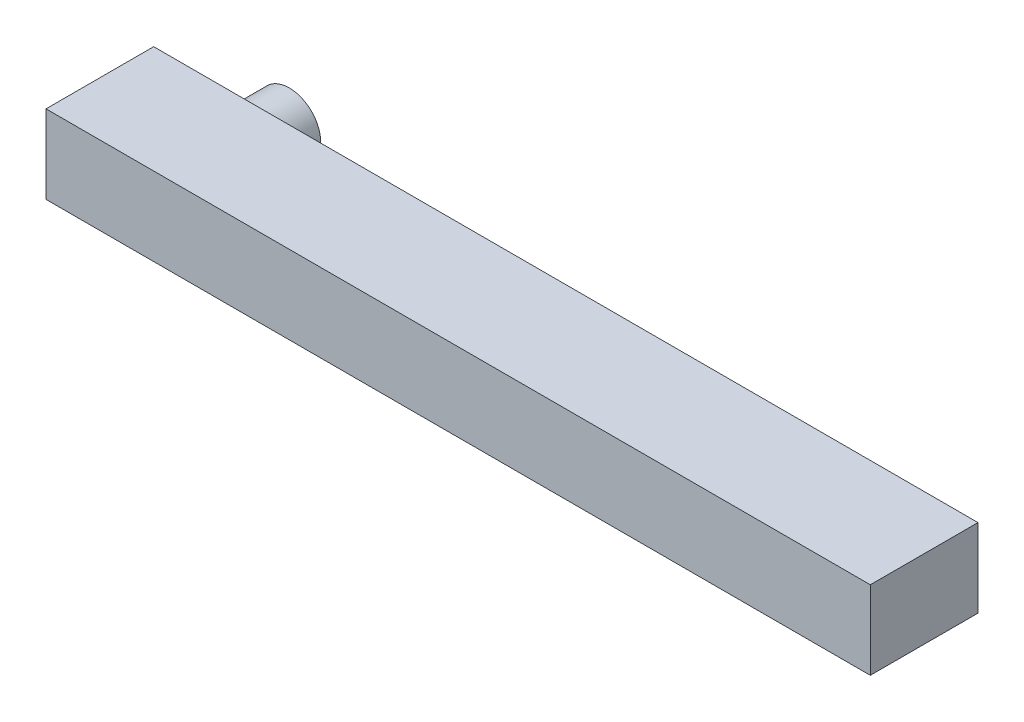
from build123d import *

# Parameters (mm, degrees)
SKETCH1_W           = 62
SKETCH1_H           = 5.9
BOSS_EXTRUDE1_DEPTH = 8.1
SKETCH4_R           = 2.365
BOSS_EXTRUDE2_DEPTH = 3


with BuildPart() as part:
    # Sketch1 → Boss-Extrude1 (new body)
    with BuildSketch(Plane.XY):
        with Locations((0, 2.95)):
            Rectangle(SKETCH1_W, SKETCH1_H)
    extrude(amount=-BOSS_EXTRUDE1_DEPTH)

    # Sketch4 → Boss-Extrude2 (add)
    with BuildSketch(Plane(origin=(0, 0, -8.1), x_dir=(-1, 0, 0), z_dir=(0, 0, -1))):
        with Locations((23.8, 2.95)):
            Circle(SKETCH4_R)
    extrude(amount=BOSS_EXTRUDE2_DEPTH)


solid = part.part
